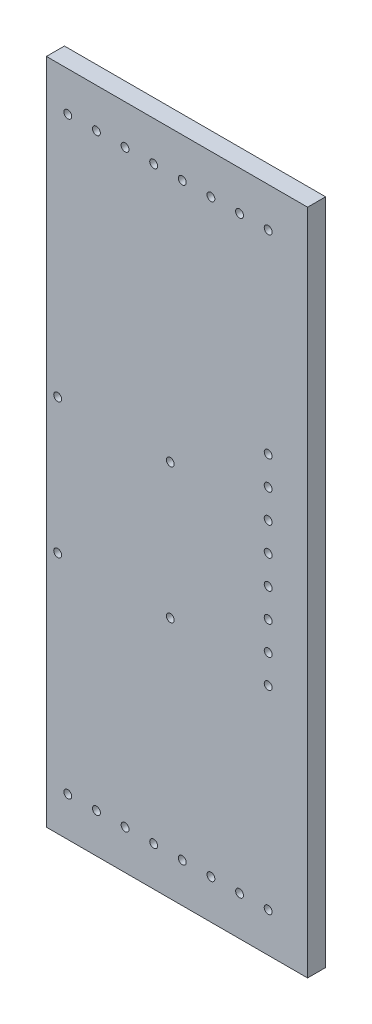
from build123d import *

# Parameters (mm, degrees)
ESBO_O1_W                 = 116
ESBO_O1_H                 = 296.5
RESSALTO_EXTRUS_O1_DEPTH  = 8
ESBO_O2_R                 = 1.75
CORTE_EXTRUS_O1_DEPTH     = 8
ESBO_O3_R                 = 1.75
CORTE_EXTRUS_O2_DEPTH     = 100
PADR_O_LINEAR1_COUNT      = 8
PADR_O_LINEAR1_PITCH      = 12.714285714
PADR_O_LINEAR1_COUNT_DIR2 = 2
PADR_O_LINEAR1_PITCH_DIR2 = 261.5
ESBO_O4_R                 = 1.75
CORTE_EXTRUS_O3_DEPTH     = 100
PADR_O_LINEAR2_COUNT      = 8
PADR_O_LINEAR2_PITCH      = 12.714285714
PADR_O_LINEAR2_COUNT_DIR2 = 2
PADR_O_LINEAR2_PITCH_DIR2 = 181.5


with BuildPart() as part:
    # Esboço1 → Ressalto-extrusão1 (new body)
    with BuildSketch(Plane.XY):
        Rectangle(ESBO_O1_W, ESBO_O1_H)
    extrude(amount=RESSALTO_EXTRUS_O1_DEPTH)

    # Esboço2 → Corte-extrusão1 (cut)
    with BuildSketch(Plane(origin=(0, 0, 0), x_dir=(-1, 0, 0), z_dir=(0, 0, -1))):
        with Locations((3, -40.25)):
            Circle(ESBO_O2_R)
        with Locations((3, 19.75)):
            Circle(ESBO_O2_R)
        with Locations((53, 19.75)):
            Circle(ESBO_O2_R)
        with Locations((53, -40.25)):
            Circle(ESBO_O2_R)
    extrude(amount=-CORTE_EXTRUS_O1_DEPTH, mode=Mode.SUBTRACT)

    # Esboço3 → Corte-extrusão2 (cut)
    with BuildSketch(Plane.XY.offset(8)):
        with Locations((-48.5, 130.75)):
            Circle(ESBO_O3_R)
    corte_extrus_o2 = extrude(amount=-CORTE_EXTRUS_O2_DEPTH, mode=Mode.SUBTRACT)

    # Padrão linear1: Corte-extrus_o2 8 × 2
    with Locations(*[(i * PADR_O_LINEAR1_PITCH, -j * PADR_O_LINEAR1_PITCH_DIR2, 0) for i in range(PADR_O_LINEAR1_COUNT) for j in range(PADR_O_LINEAR1_COUNT_DIR2) if (i, j) != (0, 0)]):
        add(corte_extrus_o2, mode=Mode.SUBTRACT)

    # Esboço4 → Corte-extrusão3 (cut)
    with BuildSketch(Plane.XY.offset(8)):
        with Locations((40.5, 44.5)):
            Circle(ESBO_O4_R)
    corte_extrus_o3 = extrude(amount=-CORTE_EXTRUS_O3_DEPTH, mode=Mode.SUBTRACT)

    # Padrão linear2: Corte-extrus_o3 8 × 2
    with Locations(*[(-j * PADR_O_LINEAR2_PITCH_DIR2, -i * PADR_O_LINEAR2_PITCH, 0) for i in range(PADR_O_LINEAR2_COUNT) for j in range(PADR_O_LINEAR2_COUNT_DIR2) if (i, j) != (0, 0)]):
        add(corte_extrus_o3, mode=Mode.SUBTRACT)


solid = part.part
